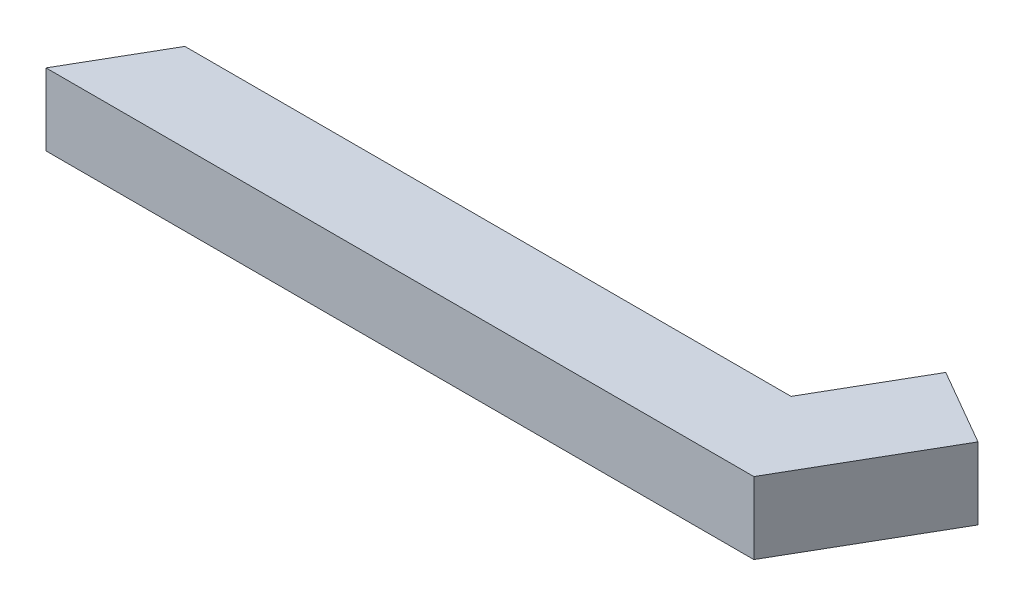
from build123d import *

# Parameters (mm, degrees)
BOSS_EXTRUDE1_DEPTH = 25.4


with BuildPart() as part:
    # Sketch1 → Boss-Extrude1 (new body)
    with BuildSketch(Plane(origin=(0, 0, 0), x_dir=(1, 0, 0), z_dir=(0, 1, 0))):
        Polygon((-123.169565917, -23.329882989), (126.830434083, -23.329882989), (108.874840712, 7.770117011), (-105.213972545, 7.770117011), align=None)
        Polygon((155.808230769, 26.861133162), (126.830434083, -23.329882989), (108.874840712, 7.770117011), (128.874840712, 42.411133162), align=None)
    extrude(amount=BOSS_EXTRUDE1_DEPTH)


solid = part.part
